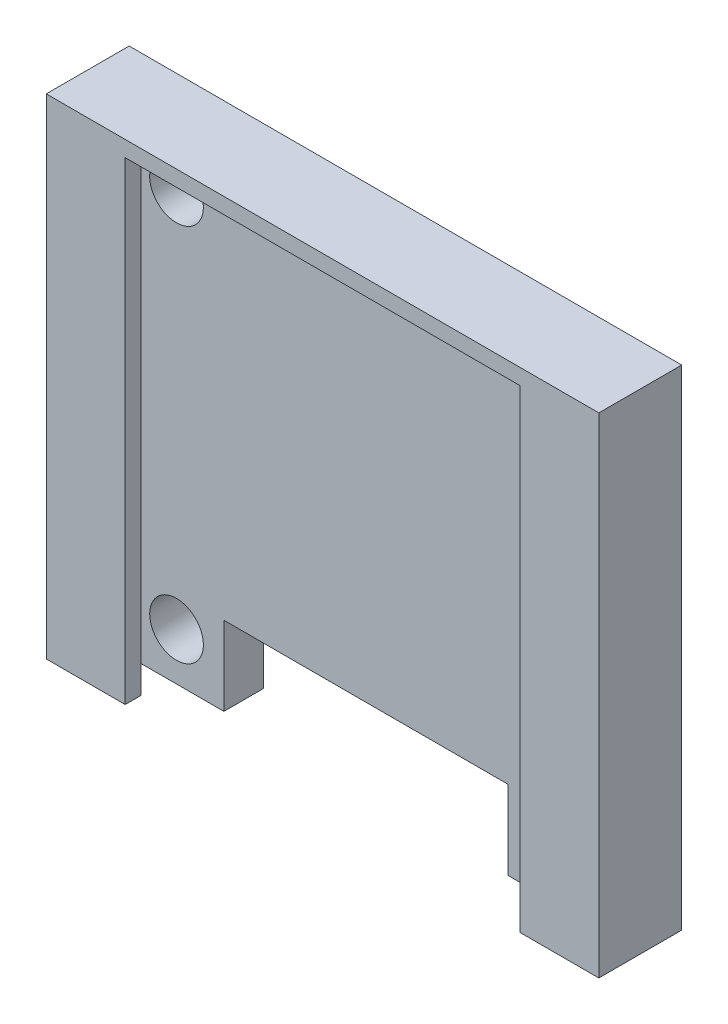
from build123d import *

# Parameters (mm, degrees)
SKETCH1_W           = 35
SKETCH1_H           = 30
SKETCH1_R           = 1.7
BOSS_EXTRUDE1_DEPTH = 2.5
SKETCH3_W           = 18
SKETCH3_H           = 5
CUT_EXTRUDE1_DEPTH  = 5
SKETCH4_W           = 2.551904925
SKETCH4_H           = 30
BOSS_EXTRUDE2_DEPTH = 1.75
SKETCH5_W           = 2.448095075
SKETCH5_H           = 30
SKETCH5_W_2         = 2.551904925
SKETCH5_W_3         = 5
BOSS_EXTRUDE3_DEPTH = 1
SKETCH6_W           = 35
SKETCH6_H           = 5.25
BOSS_EXTRUDE4_DEPTH = 1


with BuildPart() as part:
    # Sketch1 → Boss-Extrude1 (new body)
    with BuildSketch(Plane.XY):
        with Locations((17.5, 15)):
            Rectangle(SKETCH1_W, SKETCH1_H)
        with Locations((5.5, 27)):
            Circle(SKETCH1_R, mode=Mode.SUBTRACT)
        with Locations((29.5, 27)):
            Circle(SKETCH1_R, mode=Mode.SUBTRACT)
        with Locations((29.5, 3)):
            Circle(SKETCH1_R, mode=Mode.SUBTRACT)
        with Locations((5.5, 3)):
            Circle(SKETCH1_R, mode=Mode.SUBTRACT)
    extrude(amount=BOSS_EXTRUDE1_DEPTH)

    # Sketch3 → Cut-Extrude1 (cut)
    with BuildSketch(Plane.XY.offset(2.5)):
        with Locations((17.5, 2.5)):
            Rectangle(SKETCH3_W, SKETCH3_H)
    extrude(amount=-CUT_EXTRUDE1_DEPTH, mode=Mode.SUBTRACT)

    # Sketch4 → Boss-Extrude2 (add)
    with BuildSketch(Plane.XY.offset(2.5)):
        with Locations((1.275952463, 15)):
            Rectangle(SKETCH4_W, SKETCH4_H)
        with Locations((33.724047537, 15)):
            Rectangle(SKETCH4_W, SKETCH4_H)
    extrude(amount=BOSS_EXTRUDE2_DEPTH)

    # Sketch5 → Boss-Extrude3 (add)
    with BuildSketch(Plane.XY.offset(4.25)):
        with Locations((3.775952463, 15)):
            Rectangle(SKETCH5_W, SKETCH5_H)
        with Locations((1.275952463, 15)):
            Rectangle(SKETCH5_W_2, SKETCH5_H)
        with Locations((32.5, 15)):
            Rectangle(SKETCH5_W_3, SKETCH5_H)
    extrude(amount=BOSS_EXTRUDE3_DEPTH)

    # Sketch6 → Boss-Extrude4 (add)
    with BuildSketch(Plane(origin=(0, 30, 0), x_dir=(1, 0, 0), z_dir=(0, 1, 0))):
        with Locations((17.5, -2.625)):
            Rectangle(SKETCH6_W, SKETCH6_H)
    extrude(amount=BOSS_EXTRUDE4_DEPTH)


solid = part.part
